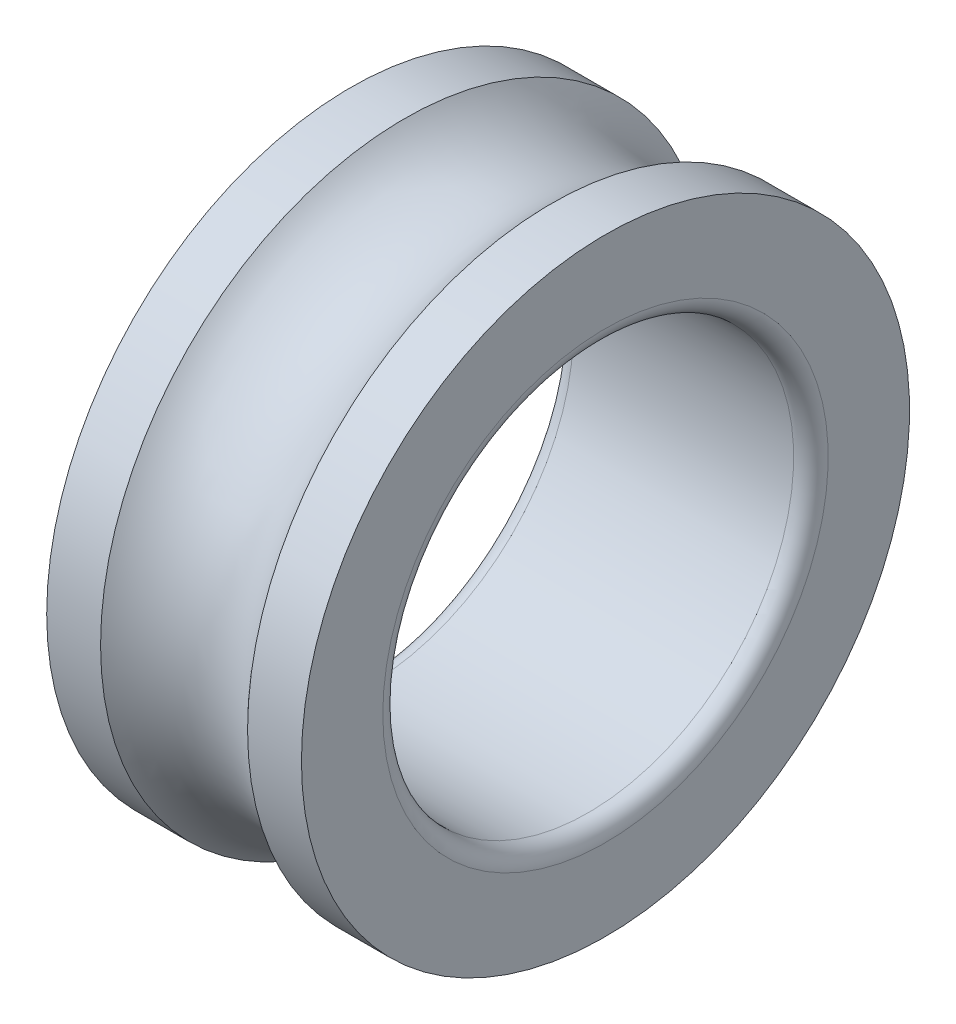
from build123d import *


with BuildPart() as part:
    # Sketch1 → Revolve1 (revolve)
    with BuildSketch(Plane.XY):
        with BuildLine():
            Line((-15.5, 37), (-15.5, 27.1))
            ThreePointArc((-15.5, 27.1), (-14.88492424, 25.61507576), (-13.4, 25))
            Line((-13.4, 25), (13.4, 25))
            ThreePointArc((13.4, 25), (14.88492424, 25.61507576), (15.5, 27.1))
            Line((15.5, 27.1), (15.5, 37))
            Line((15.5, 37), (8.94427191, 37))
            ThreePointArc((8.94427191, 37), (0, 33), (-8.94427191, 37))
            Line((-8.94427191, 37), (-15.5, 37))
        make_face()
    revolve(axis=Axis((-11.869369369, 0, 0), (1, 0, 0)))


solid = part.part
